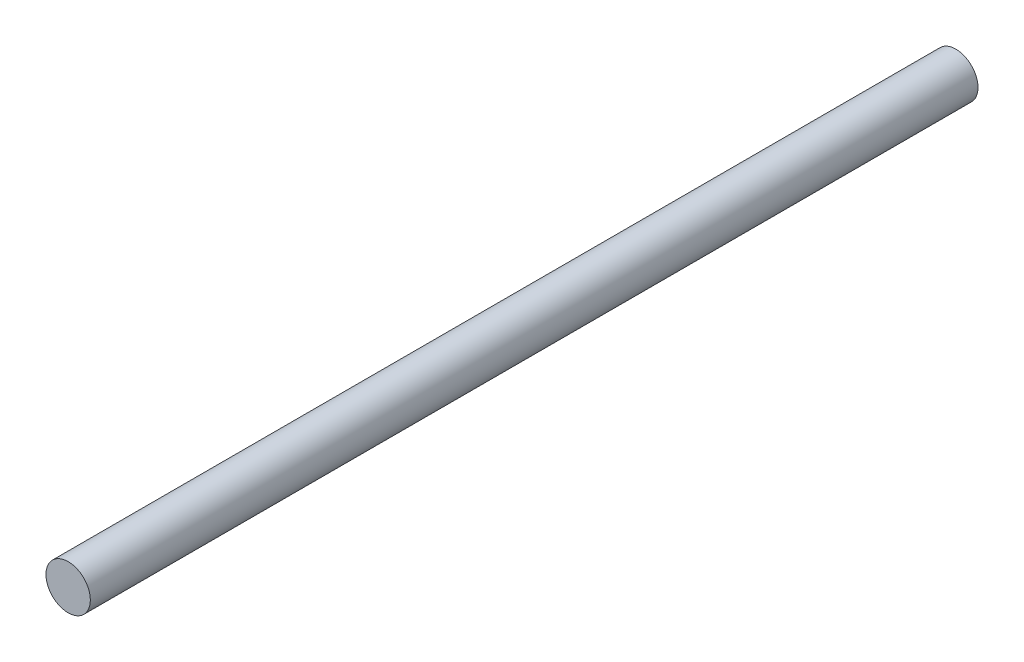
from build123d import *

# Parameters (mm, degrees)
SKETCH1_R           = 0.79375
BOSS_EXTRUDE1_DEPTH = 31.75


with BuildPart() as part:
    # Sketch1 → Boss-Extrude1 (new body)
    with BuildSketch(Plane.XY):
        Circle(SKETCH1_R)
    extrude(amount=BOSS_EXTRUDE1_DEPTH)


solid = part.part
